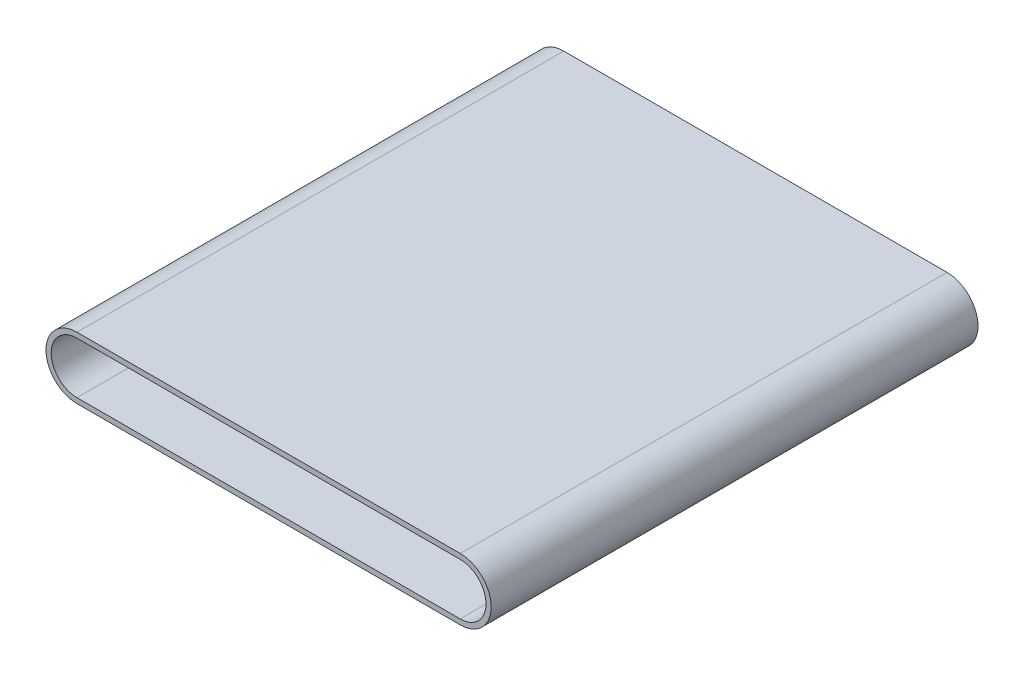
from build123d import *

# Parameters (mm, degrees)
SKETCH3_W = 470
SKETCH3_H = 5


with BuildPart() as part:
    # Sweep2: sweep along a path in Sketch2
    with BuildLine(Plane.XY) as sweep2_path:
        Line((0, -24.875), (-370, -24.875))
        ThreePointArc((-370, -24.875), (-394.875, 0), (-370, 24.875))
        Line((-370, 24.875), (0, 24.875))
        ThreePointArc((0, 24.875), (24.875, 0), (0, -24.875))
    # Sketch3 → Sweep2 (sweep)
    with BuildSketch(Plane(origin=(0, 0, 0), x_dir=(0, 0, -1), z_dir=(1, 0, 0))):
        with Locations((0, 27.375)):
            Rectangle(SKETCH3_W, SKETCH3_H)
    sweep(path=sweep2_path.line)


solid = part.part
